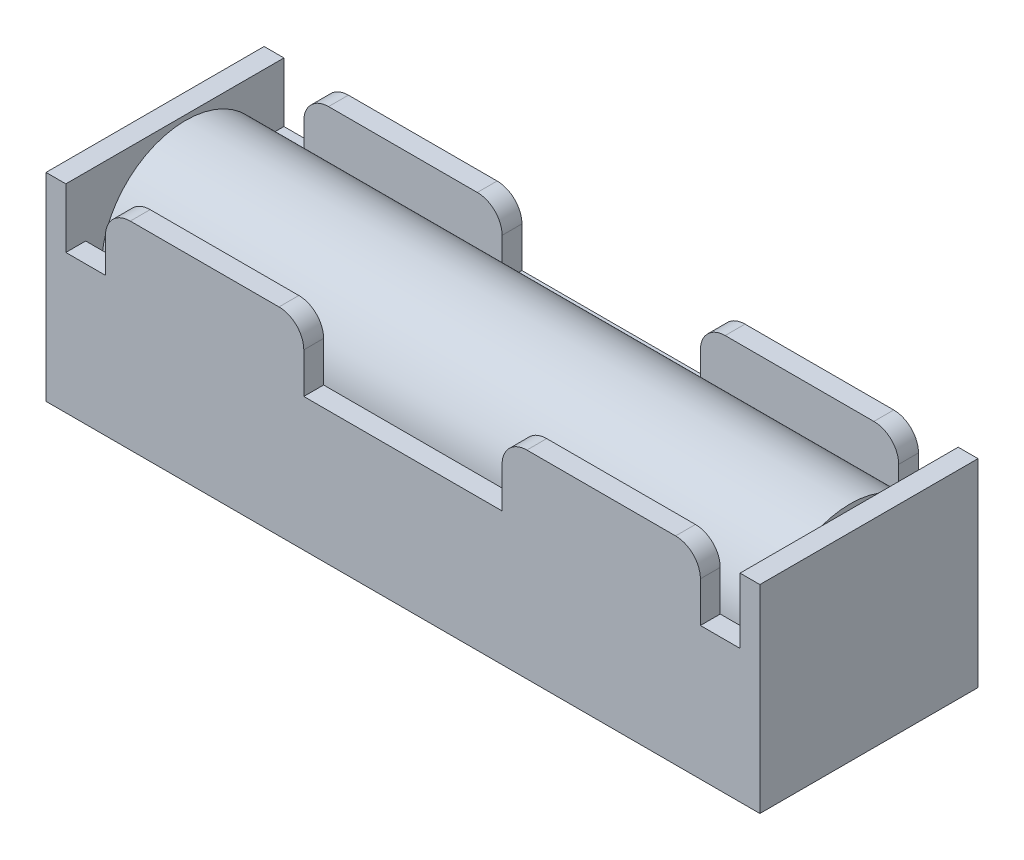
from build123d import *

# Parameters (mm, degrees)
SKETCH1_W           = 72
SKETCH1_H           = 22
BOSS_EXTRUDE1_DEPTH = 20
SKETCH2_W           = 68
SKETCH2_H           = 18
CUT_EXTRUDE1_DEPTH  = 18
CUT_EXTRUDE2_DEPTH  = 30
SKETCH5_R           = 8.5
BOSS_EXTRUDE3_DEPTH = 67


with BuildPart() as part:
    # Sketch1 → Boss-Extrude1 (new body)
    with BuildSketch(Plane(origin=(0, 0, 0), x_dir=(1, 0, 0), z_dir=(0, 1, 0))):
        with Locations((-12.388663968, 12.75708502)):
            Rectangle(SKETCH1_W, SKETCH1_H)
    extrude(amount=BOSS_EXTRUDE1_DEPTH)

    # Sketch2 → Cut-Extrude1 (cut)
    with BuildSketch(Plane(origin=(0, 20, 0), x_dir=(1, 0, 0), z_dir=(0, 1, 0))):
        with Locations((-12.388663968, 12.75708502)):
            Rectangle(SKETCH2_W, SKETCH2_H)
    extrude(amount=-CUT_EXTRUDE1_DEPTH, mode=Mode.SUBTRACT)

    # Sketch4 → Cut-Extrude2 (cut)
    with BuildSketch(Plane.XY.offset(-1.75708502)):
        with BuildLine():
            Line((-46.388663968, 20), (-46.388663968, 14.00702655))
            Line((-46.388663968, 14.00702655), (-42.387974224, 14.00702655))
            Line((-42.387974224, 14.00702655), (-42.387974224, 17.5))
            ThreePointArc((-42.387974224, 17.5), (-41.655741177, 19.267766953), (-39.887974224, 20))
            Line((-39.887974224, 20), (-46.388663968, 20))
        make_face()
        with BuildLine():
            Line((0.111336032, 20), (-24.887974224, 20))
            ThreePointArc((-24.887974224, 20), (-23.120694993, 19.267968974), (-22.388663968, 17.500689744))
            Line((-22.388663968, 17.500689744), (-22.388663968, 13.429648774))
            Line((-22.388663968, 13.429648774), (-2.388663968, 13.429648774))
            Line((-2.388663968, 13.429648774), (-2.388663968, 17.5))
            ThreePointArc((-2.388663968, 17.5), (-1.656430921, 19.267766953), (0.111336032, 20))
        make_face()
        with BuildLine():
            Line((21.611336032, 20), (15.111336032, 20))
            ThreePointArc((15.111336032, 20), (16.879102985, 19.267766953), (17.611336032, 17.5))
            Line((17.611336032, 17.5), (17.611336032, 13.424239873))
            Line((17.611336032, 13.424239873), (21.611336032, 13.424239873))
            Line((21.611336032, 13.424239873), (21.611336032, 20))
        make_face()
    extrude(amount=-CUT_EXTRUDE2_DEPTH, mode=Mode.SUBTRACT)

    # Sketch5 → Boss-Extrude3 (add)
    with BuildSketch(Plane.ZY.offset(-21.611336032)):
        with Locations((-12.859898676, 12)):
            Circle(SKETCH5_R)
    extrude(amount=BOSS_EXTRUDE3_DEPTH)


solid = part.part
